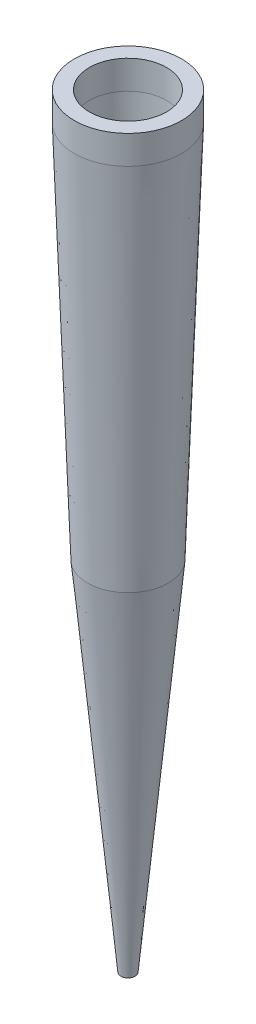
from build123d import *


with BuildPart() as part:
    # Skizze1 → Rotation1 (revolve)
    with BuildSketch(Plane.XY):
        Polygon((-2.7, 0), (-2.7, -2), (-1.774599608, -28.5), (-0.5, -53.5), (-2.824599608, -28.5), (-3.75, -2), (-3.75, 0), align=None)
    revolve(axis=Axis((0, 0, 0), (0, -1, 0)))


solid = part.part
